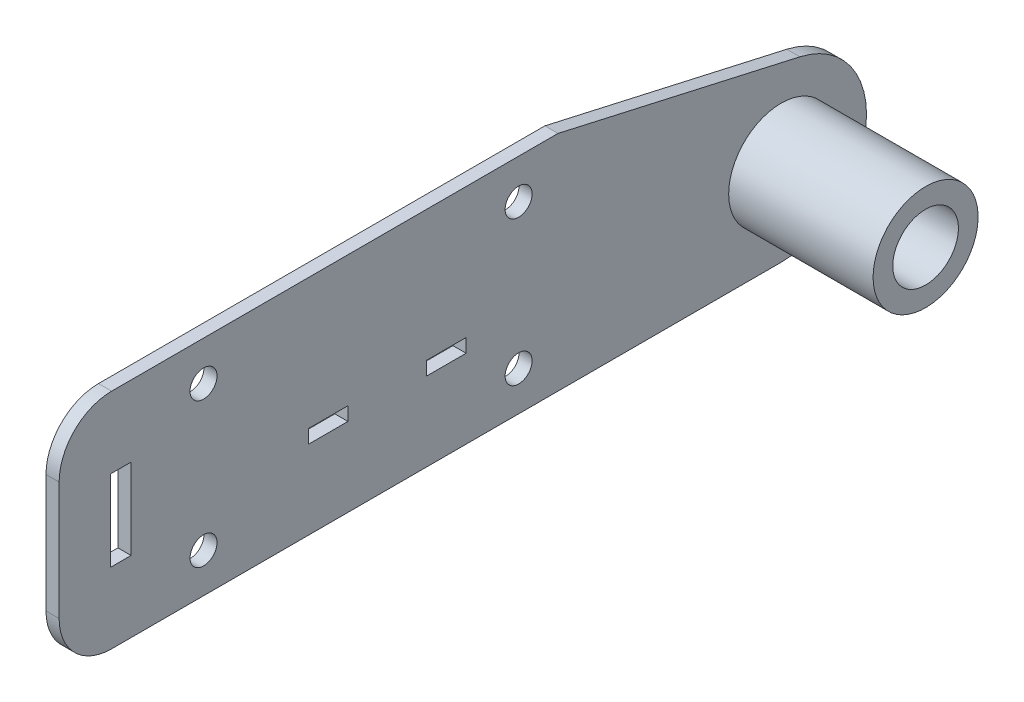
from build123d import *

# Parameters (mm, degrees)
SKETCH1_R           = 3.2639
SKETCH1_R_2         = 12.7
BOSS_EXTRUDE1_DEPTH = 3.175
SKETCH2_R           = 12.7
SKETCH2_R_2         = 7.9375
BOSS_EXTRUDE2_DEPTH = 38.1
SKETCH4_W           = 4.953
SKETCH4_H           = 19.558
BOSS_EXTRUDE3_DEPTH = 3.175
SKETCH5_W           = 9.525
SKETCH5_H           = 3.302
CUT_EXTRUDE1_DEPTH  = 4.175


with BuildPart() as part:
    # Sketch1 → Boss-Extrude1 (new body)
    with BuildSketch(Plane(origin=(0, 0, 0), x_dir=(0, 0, -1), z_dir=(1, 0, 0))):
        with BuildLine():
            Line((106.143178695, 13.781217887), (47.625, 26.9875))
            Line((47.625, 26.9875), (-47.625, 26.9875))
            Line((-47.625, 26.9875), (-47.625, -26.9875))
            Line((-47.625, -26.9875), (101.6, -26.9875))
            ThreePointArc((101.6, -26.9875), (122.110538942, -8.635650576), (106.143178695, 13.781217887))
        make_face()
        with Locations((38.1, 17.4625)):
            Circle(SKETCH1_R, mode=Mode.SUBTRACT)
        with Locations((38.1, -17.4625)):
            Circle(SKETCH1_R, mode=Mode.SUBTRACT)
        with Locations((-38.1, -17.4625)):
            Circle(SKETCH1_R, mode=Mode.SUBTRACT)
        with Locations((-38.1, 17.4625)):
            Circle(SKETCH1_R, mode=Mode.SUBTRACT)
        with Locations((101.6, -6.35)):
            Circle(SKETCH1_R_2, mode=Mode.SUBTRACT)
    extrude(amount=BOSS_EXTRUDE1_DEPTH)

    # Sketch2 → Boss-Extrude2 (add)
    with BuildSketch(Plane.ZY):
        with Locations((-101.6, -6.35)):
            Circle(SKETCH2_R)
        with Locations((-101.6, -6.35)):
            Circle(SKETCH2_R_2, mode=Mode.SUBTRACT)
    extrude(amount=-BOSS_EXTRUDE2_DEPTH)

    # Sketch4 → Boss-Extrude3 (add)
    with BuildSketch(Plane(origin=(3.175, 0, 0), x_dir=(0, 0, -1), z_dir=(1, 0, 0))):
        with BuildLine():
            Line((-47.625, 26.9875), (-60.325, 26.9875))
            ThreePointArc((-60.325, 26.9875), (-69.305256121, 23.267756121), (-73.025, 14.2875))
            Line((-73.025, 14.2875), (-73.025, -14.2875))
            ThreePointArc((-73.025, -14.2875), (-69.305256121, -23.267756121), (-60.325, -26.9875))
            Line((-60.325, -26.9875), (-47.625, -26.9875))
            Line((-47.625, -26.9875), (-47.625, 26.9875))
        make_face()
        with Locations((-58.1025, 0)):
            Rectangle(SKETCH4_W, SKETCH4_H, mode=Mode.SUBTRACT)
    extrude(amount=-BOSS_EXTRUDE3_DEPTH)

    # Sketch5 → Cut-Extrude1 (cut, through all)
    with BuildSketch(Plane(origin=(3.175, 0, 0), x_dir=(0, 0, -1), z_dir=(1, 0, 0))):
        with Locations((20.6375, -6.2865)):
            Rectangle(SKETCH5_W, SKETCH5_H)
        with Locations((-7.9375, -6.2865)):
            Rectangle(SKETCH5_W, SKETCH5_H)
    extrude(amount=-CUT_EXTRUDE1_DEPTH, mode=Mode.SUBTRACT)


solid = part.part
